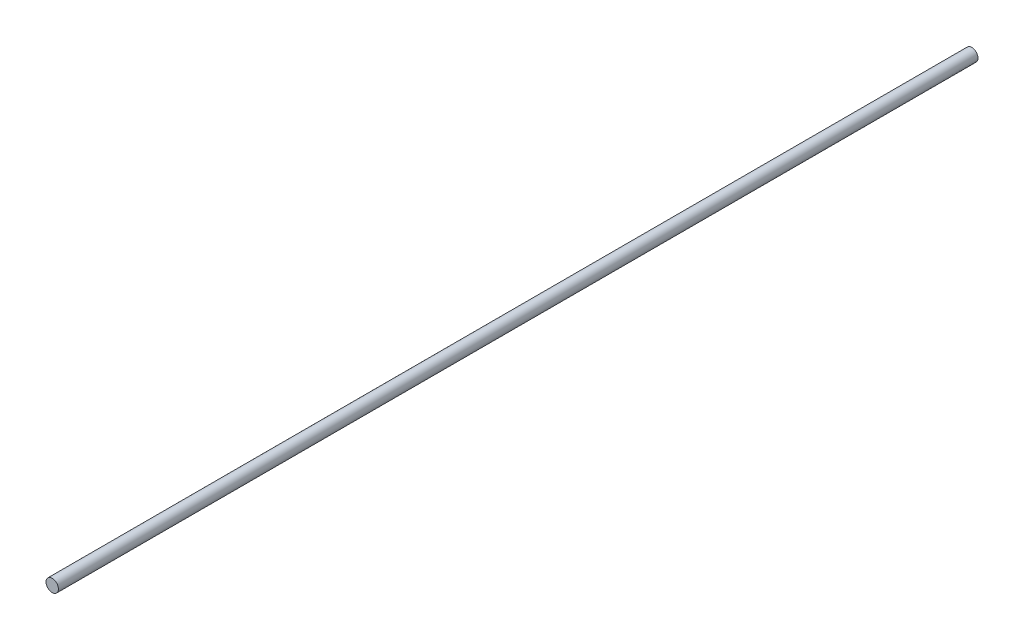
from build123d import *

# Parameters (mm, degrees)
SKETCH1_R           = 2.5
BOSS_EXTRUDE1_DEPTH = 370


with BuildPart() as part:
    # Sketch1 → Boss-Extrude1 (new body)
    with BuildSketch(Plane.XY):
        Circle(SKETCH1_R)
    extrude(amount=BOSS_EXTRUDE1_DEPTH)


solid = part.part
